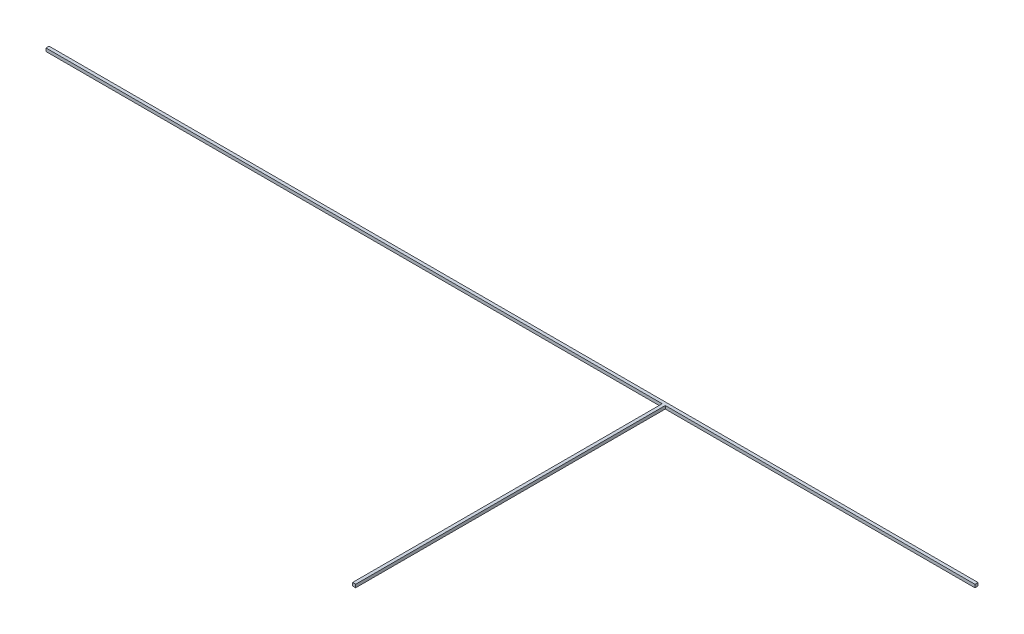
from build123d import *

# Parameters (mm, degrees)
SKETCH1_W           = 1
SKETCH1_H           = 1
BOSS_EXTRUDE1_DEPTH = 300
SKETCH2_W           = 1
SKETCH2_H           = 1
BOSS_EXTRUDE2_DEPTH = 100


with BuildPart() as part:
    # Sketch1 → Boss-Extrude1 (new body)
    with BuildSketch(Plane(origin=(0, 0, 0), x_dir=(0, 0, -1), z_dir=(1, 0, 0))):
        with Locations((0.137681159, -0.057971014)):
            Rectangle(SKETCH1_W, SKETCH1_H)
    extrude(amount=BOSS_EXTRUDE1_DEPTH)

    # Sketch2 → Boss-Extrude2 (add)
    with BuildSketch(Plane.XY.offset(0.362318841)):
        with Locations((199.5, -0.057971014)):
            Rectangle(SKETCH2_W, SKETCH2_H)
    extrude(amount=BOSS_EXTRUDE2_DEPTH)


solid = part.part
